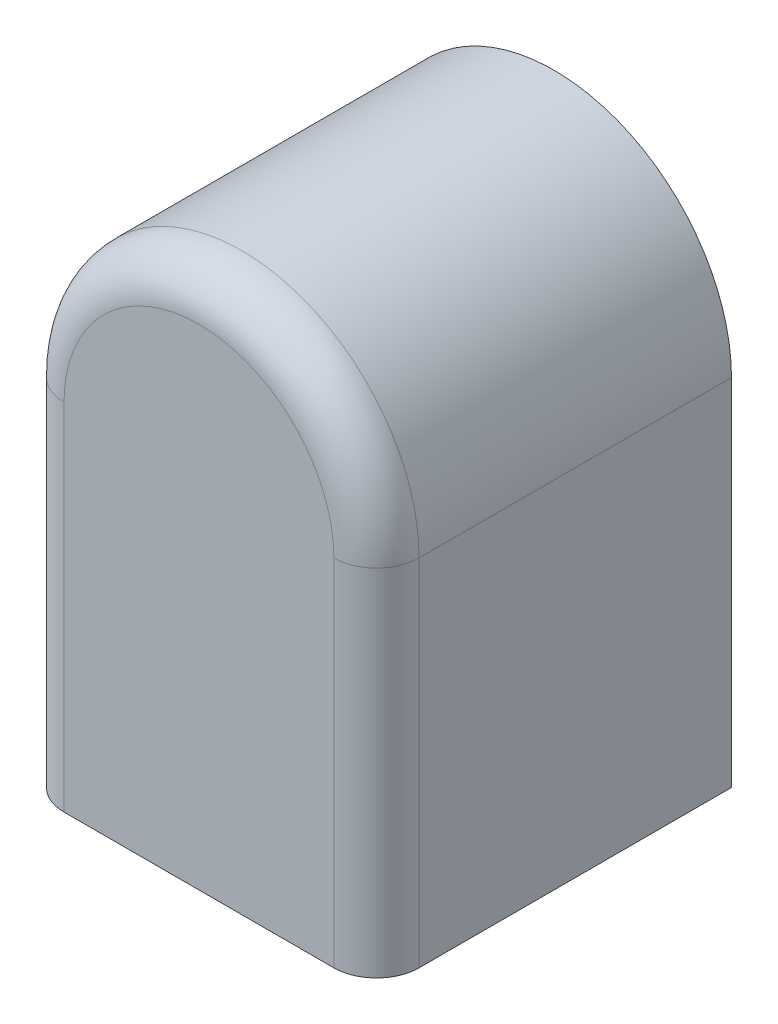
from build123d import *

# Parameters (mm, degrees)
EXTRUDE_1_DEPTH = 25
FILLET_1_R      = 3


with BuildPart() as part:
    # Эскиз1 → Бобышка-Вытянуть1 (new body)
    with BuildSketch(Plane.XY):
        with BuildLine():
            Line((-12.5, 0), (-12.5, -25))
            Line((-12.5, -25), (12.5, -25))
            Line((12.5, -25), (12.5, 0))
            ThreePointArc((12.5, 0), (0, 12.5), (-12.5, 0))
        make_face()
    extrude(amount=EXTRUDE_1_DEPTH)

    # Скругление1
    fillet_1_edges = [part.edges().sort_by_distance(p)[0] for p in [
        (12.5, -12.5, 25),
        (0, 12.5, 25),
        (-12.5, -12.5, 25),
    ]]
    fillet(fillet_1_edges, radius=FILLET_1_R)


solid = part.part
